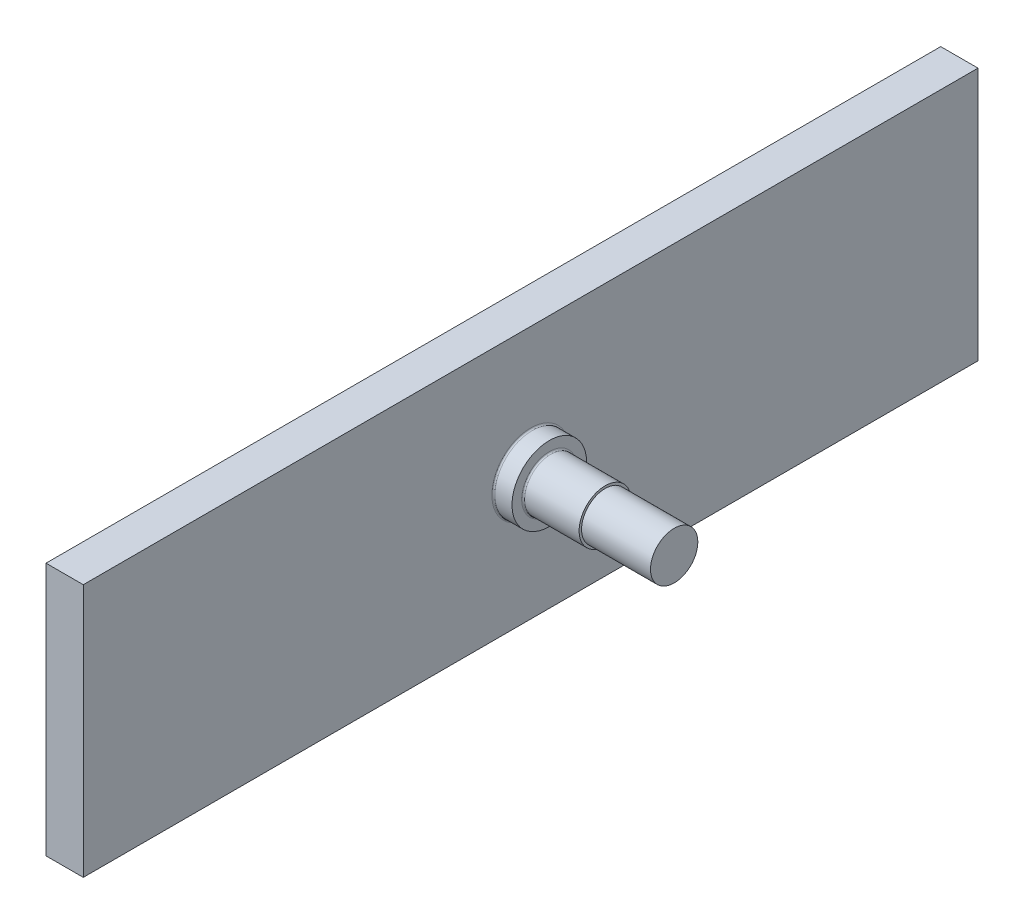
from build123d import *

# Parameters (mm, degrees)
SKETCH1_W           = 120
SKETCH1_H           = 34
BOSS_EXTRUDE1_DEPTH = 5
BOSS_EXTRUDE2_DEPTH = 2.5
SKETCH3_R           = 3.5
BOSS_EXTRUDE3_DEPTH = 16.75
SKETCH4_R           = 3.5
SKETCH4_R_2         = 3.175
CUT_EXTRUDE1_DEPTH  = 9.25
FILLET1_R           = 0.2


with BuildPart() as part:
    # Sketch1 → Boss-Extrude1 (new body)
    with BuildSketch(Plane(origin=(0, 0, 0), x_dir=(0, 0, -1), z_dir=(1, 0, 0))):
        with Locations((-60, 17)):
            Rectangle(SKETCH1_W, SKETCH1_H)
    extrude(amount=BOSS_EXTRUDE1_DEPTH)

    # Sketch2 → Boss-Extrude2 (add)
    with BuildSketch(Plane(origin=(5, 0, 0), x_dir=(0, 0, -1), z_dir=(1, 0, 0))):
        with BuildLine():
            ThreePointArc((-55, 17), (-56.464466094, 20.535533906), (-60, 22))
            Line((-60, 22), (-60, 12))
            ThreePointArc((-60, 12), (-56.464466094, 13.464466094), (-55, 17))
        make_face()
        with BuildLine():
            Line((-60, 12), (-60, 22))
            ThreePointArc((-60, 22), (-65, 17), (-60, 12))
        make_face()
    extrude(amount=BOSS_EXTRUDE2_DEPTH)

    # Sketch3 → Boss-Extrude3 (add)
    with BuildSketch(Plane(origin=(7.5, 0, 0), x_dir=(0, 0, -1), z_dir=(1, 0, 0))):
        with Locations((-60, 17)):
            Circle(SKETCH3_R)
    extrude(amount=BOSS_EXTRUDE3_DEPTH)

    # Sketch4 → Cut-Extrude1 (cut)
    with BuildSketch(Plane(origin=(24.25, 0, 0), x_dir=(0, 0, -1), z_dir=(1, 0, 0))):
        with Locations((-60, 17)):
            Circle(SKETCH4_R)
        with Locations((-60, 17)):
            Circle(SKETCH4_R_2, mode=Mode.SUBTRACT)
    extrude(amount=-CUT_EXTRUDE1_DEPTH, mode=Mode.SUBTRACT)

    # Fillet1
    fillet1_edges = [part.edges().sort_by_distance(p)[0] for p in [
        (5, 12, 60),
        (7.5, 17, 63.5),
    ]]
    fillet(fillet1_edges, radius=FILLET1_R)


solid = part.part
